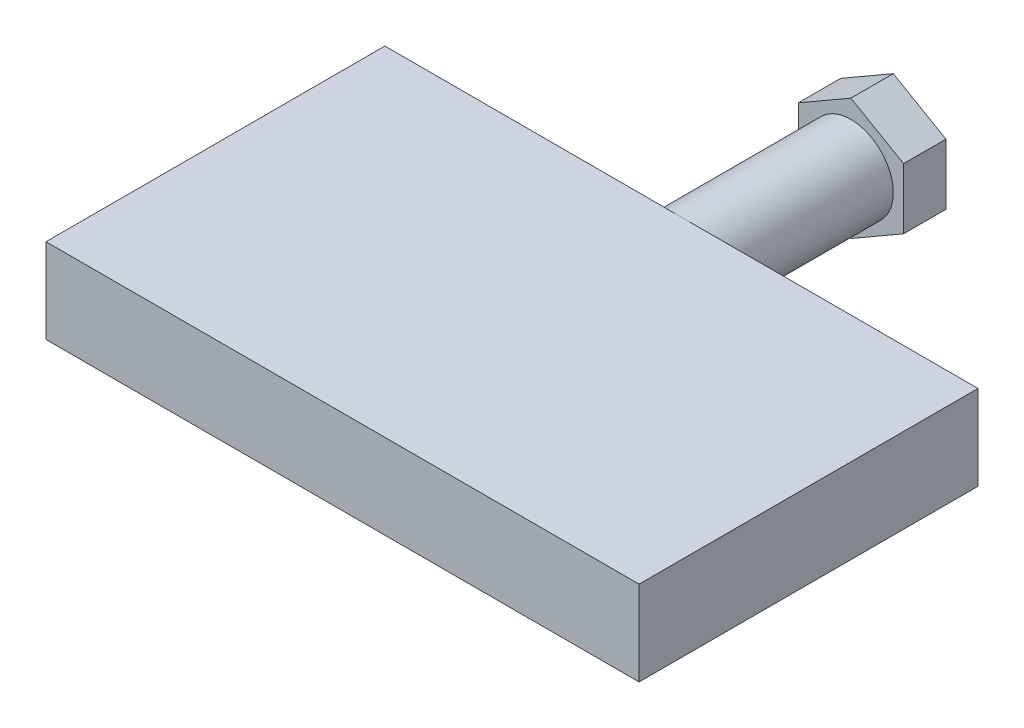
from build123d import *

# Parameters (mm, degrees)
BOSS_EXTRUDE1_DEPTH = 10
SKETCH2_R           = 5
BOSS_EXTRUDE2_DEPTH = 20
BOSS_EXTRUDE4_DEPTH = 5


with BuildPart() as part:
    # Sketch1 → Boss-Extrude1 (new body)
    with BuildSketch(Plane(origin=(0, 0, 0), x_dir=(1, 0, 0), z_dir=(0, 1, 0))):
        Polygon((-35, 40.657635654), (0, 40.657635654), (35, 40.657635654), (35, 0.657635654), (-35, 0.657635654), align=None)
    extrude(amount=BOSS_EXTRUDE1_DEPTH)

    # Sketch2 → Boss-Extrude2 (add)
    with BuildSketch(Plane(origin=(0, 0, -40.657635654), x_dir=(-1, 0, 0), z_dir=(0, 0, -1))):
        with Locations((0, 5)):
            Circle(SKETCH2_R)
    extrude(amount=BOSS_EXTRUDE2_DEPTH)

    # Sketch3 → Boss-Extrude4 (add)
    with BuildSketch(Plane(origin=(0, 0, -60.657635654), x_dir=(-1, 0, 0), z_dir=(0, 0, -1))):
        Polygon((0, -2.176119405), (6.214701705, 1.411940298), (6.214701705, 8.588059702), (0, 12.176119405), (-6.214701705, 8.588059702), (-6.214701705, 1.411940298), align=None)
    extrude(amount=BOSS_EXTRUDE4_DEPTH)


solid = part.part
